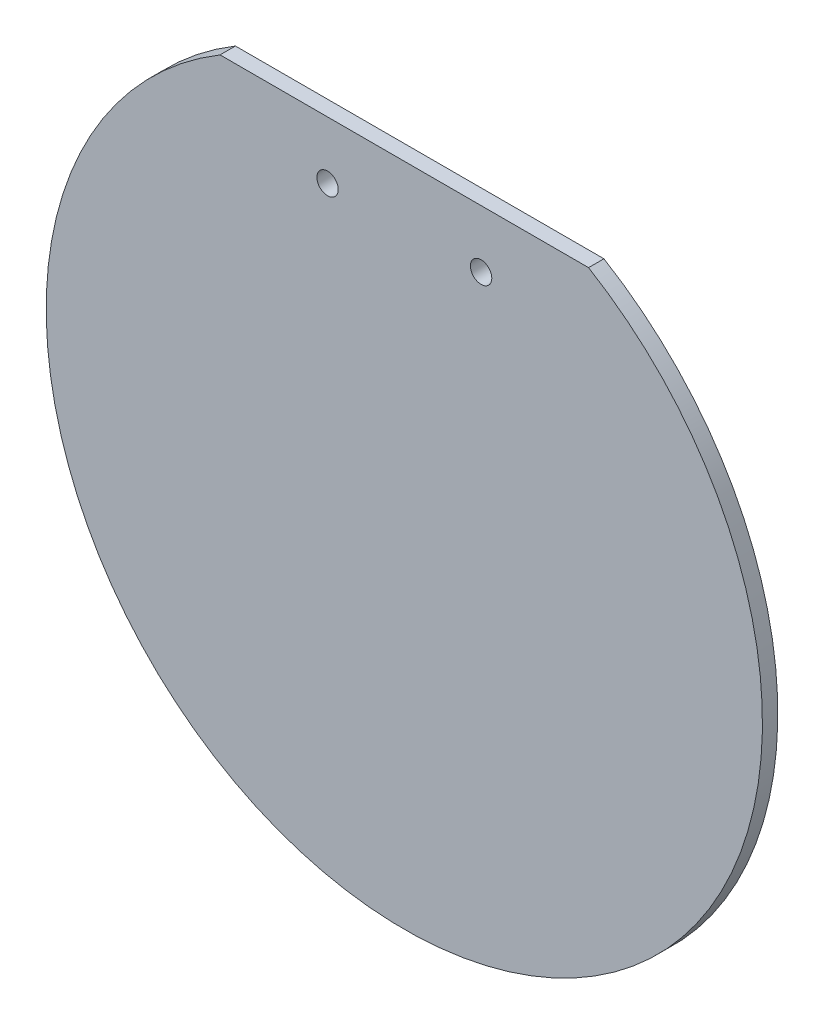
from build123d import *

# Parameters (mm, degrees)
BOSS_EXTRUDE1_DEPTH = 1.5875
SKETCH3_R           = 1.1049
CUT_EXTRUDE1_DEPTH  = 2.5875


with BuildPart() as part:
    # Sketch1 → Boss-Extrude1 (new body)
    with BuildSketch(Plane.XY):
        with BuildLine():
            Line((-19.05, 31.75), (19.05, 31.75))
            ThreePointArc((19.05, 31.75), (0, -37.026544532), (-19.05, 31.75))
        make_face()
    extrude(amount=BOSS_EXTRUDE1_DEPTH)

    # Sketch3 → Cut-Extrude1 (cut, through all)
    with BuildSketch(Plane.XY.offset(1.5875)):
        with Locations((7.9375, 25.79624)):
            Circle(SKETCH3_R)
        with Locations((-7.9375, 25.79624)):
            Circle(SKETCH3_R)
    extrude(amount=-CUT_EXTRUDE1_DEPTH, mode=Mode.SUBTRACT)


solid = part.part
